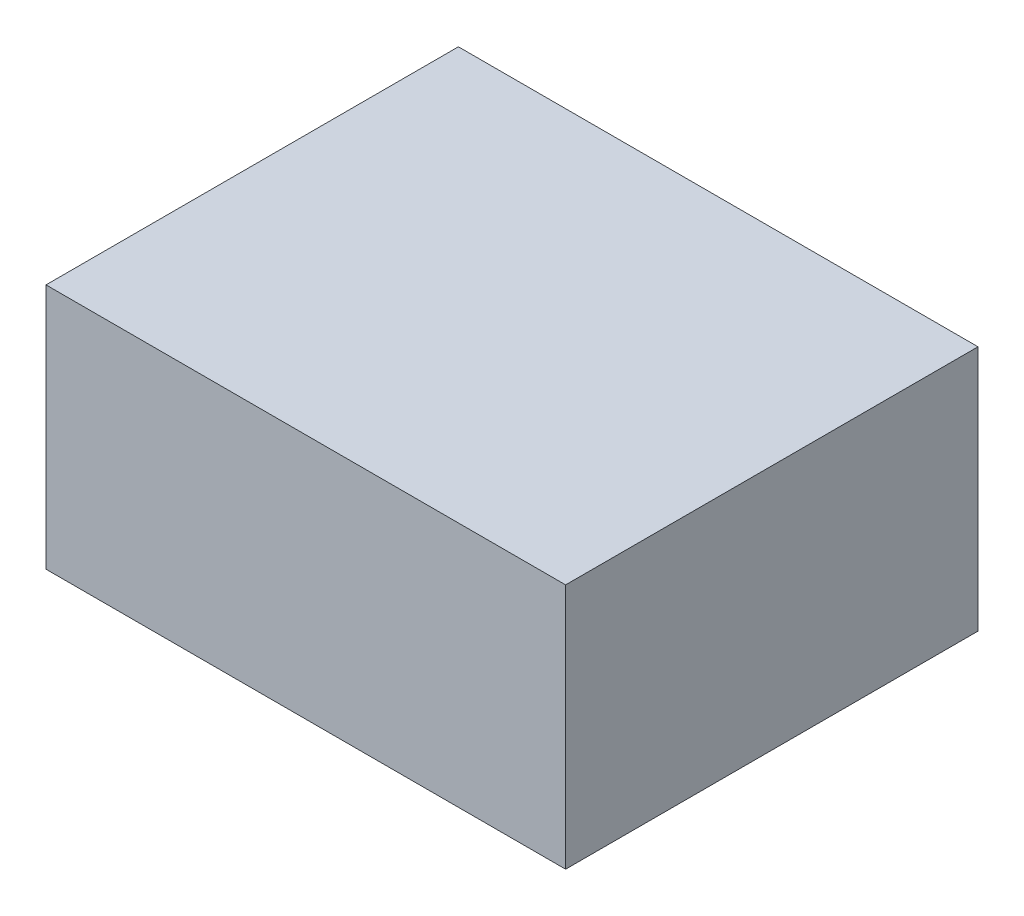
from build123d import *

# Parameters (mm, degrees)
SKETCH_34_W         = 44.1
SKETCH_34_H         = 35
EXTRUDE_1_DEPTH     = 20.9
SKETCH_35_W         = 8
SKETCH_35_H         = 8
EXTRUDE_2_DEPTH     = 109.1
SKETCH_36_W         = 3
SKETCH_36_H         = 3
EXTRUDE_3_DEPTH     = 109
SKETCH_37_W         = 130
SKETCH_37_H         = 130
CUT_EXTRUDE_1_DEPTH = 219.1


with BuildPart() as part:
    # ｽｹｯﾁ34 → ﾎﾞｽ - 押し出し1 (new body)
    with BuildSketch(Plane(origin=(0, 0, 0), x_dir=(1, 0, 0), z_dir=(0, 1, 0))):
        Rectangle(SKETCH_34_W, SKETCH_34_H)
    extrude(amount=EXTRUDE_1_DEPTH)

    # ｽｹｯﾁ35 → ﾎﾞｽ - 押し出し2 (add)
    with BuildSketch(Plane(origin=(0, 20.9, 0), x_dir=(1, 0, 0), z_dir=(0, 1, 0))):
        Rectangle(SKETCH_35_W, SKETCH_35_H)
    extrude(amount=EXTRUDE_2_DEPTH)

    # ｽｹｯﾁ36 → ﾎﾞｽ - 押し出し3 (add)
    with BuildSketch(Plane(origin=(0, 130, 0), x_dir=(1, 0, 0), z_dir=(0, 1, 0))):
        Rectangle(SKETCH_36_W, SKETCH_36_H)
    extrude(amount=EXTRUDE_3_DEPTH)

    # ｽｹｯﾁ37 → ｶｯﾄ - 押し出し1 (cut, through all)
    with BuildSketch(Plane(origin=(0, 20.9, 0), x_dir=(1, 0, 0), z_dir=(0, 1, 0))):
        Rectangle(SKETCH_37_W, SKETCH_37_H)
    extrude(amount=CUT_EXTRUDE_1_DEPTH, mode=Mode.SUBTRACT)


solid = part.part
